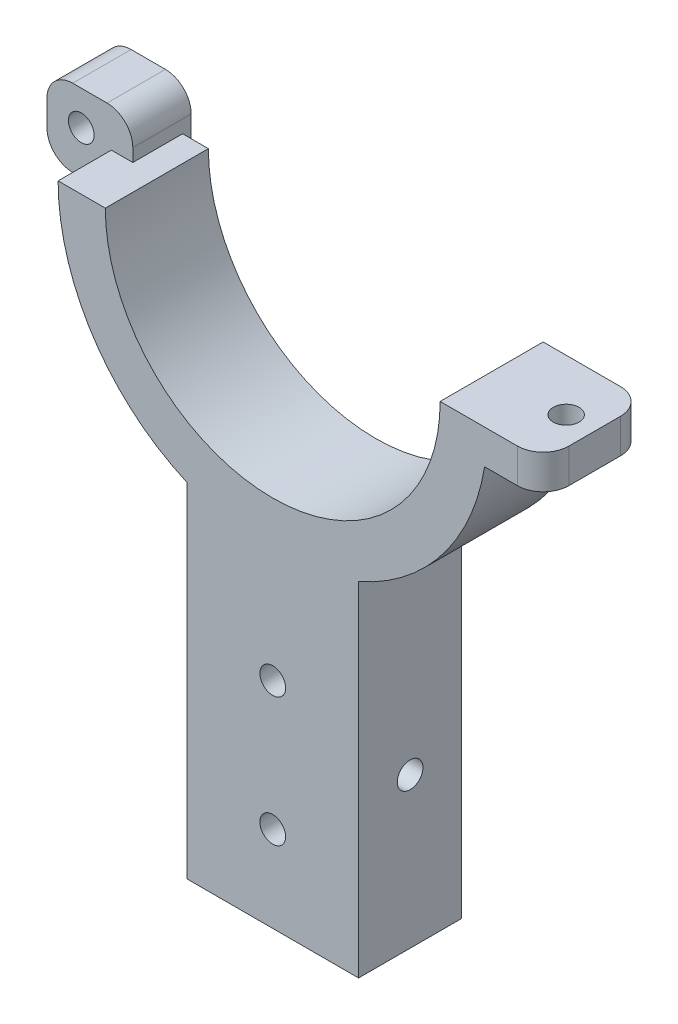
from build123d import *

# Parameters (mm, degrees)
BOSS_EXTRUDE8_DEPTH      = 12
SKETCH2_W                = 10
SKETCH2_H                = 9
BOSS_EXTRUDE9_DEPTH      = 1
BOSS_EXTRUDE9_DEPTH_BACK = 5.8
SKETCH3_R                = 1.5
CUT_EXTRUDE1_DEPTH       = 10
SKETCH4_W                = 8
SKETCH4_H                = 4
BOSS_EXTRUDE10_DEPTH     = 12
SKETCH5_R                = 1.5
CUT_EXTRUDE2_DEPTH       = 12
FILLET2_R                = 3
FILLET3_R                = 3
FILLET4_R                = 3
FILLET5_R                = 3
FILLET6_R                = 3
SKETCH6_R                = 1.5
CUT_EXTRUDE4_DEPTH       = 20
SKETCH7_R                = 1.5
CUT_EXTRUDE5_DEPTH       = 30


with BuildPart() as part:
    # Sketch1 → Boss-Extrude8 (new body)
    with BuildSketch(Plane.XY):
        with BuildLine():
            Line((25, 0), (19.5, 0))
            ThreePointArc((19.5, 0), (0, -19.5), (-19.5, 0))
            Line((-19.5, 0), (-25, 0))
            ThreePointArc((-25, 0), (-20.916500663, -13.693063938), (-10, -22.912878475))
            ThreePointArc((-10, -22.912878475), (0, -25), (10, -22.912878475))
            ThreePointArc((10, -22.912878475), (20.916500663, -13.693063938), (25, 0))
        make_face()
        with BuildLine():
            Line((10, -62.912878475), (10, -22.912878475))
            ThreePointArc((10, -22.912878475), (0, -25), (-10, -22.912878475))
            Line((-10, -22.912878475), (-10, -62.912878475))
            Line((-10, -62.912878475), (10, -62.912878475))
        make_face()
    extrude(amount=BOSS_EXTRUDE8_DEPTH)

    # Sketch2 → Boss-Extrude9 (add, two sides)
    with BuildSketch(Plane(origin=(0, 0, 0), x_dir=(-1, 0, 0), z_dir=(0, 0, -1))) as boss_extrude9_sk:
        with Locations((27.5, 0)):
            Rectangle(SKETCH2_W, SKETCH2_H)
    extrude(amount=BOSS_EXTRUDE9_DEPTH)
    extrude(boss_extrude9_sk.sketch, amount=-BOSS_EXTRUDE9_DEPTH_BACK)

    # Sketch3 → Cut-Extrude1 (cut)
    with BuildSketch(Plane(origin=(0, 0, -1), x_dir=(-1, 0, 0), z_dir=(0, 0, -1))):
        with Locations((28.5, 0.5)):
            Circle(SKETCH3_R)
    extrude(amount=-CUT_EXTRUDE1_DEPTH, mode=Mode.SUBTRACT)

    # Sketch4 → Boss-Extrude10 (add)
    with BuildSketch(Plane(origin=(0, 0, 0), x_dir=(-1, 0, 0), z_dir=(0, 0, -1))):
        with Locations((-27.5, -2)):
            Rectangle(SKETCH4_W, SKETCH4_H)
    extrude(amount=-BOSS_EXTRUDE10_DEPTH)

    # Sketch5 → Cut-Extrude2 (cut)
    with BuildSketch(Plane.XZ.offset(4)):
        with Locations((28.177925359, 6)):
            Circle(SKETCH5_R)
    extrude(amount=-CUT_EXTRUDE2_DEPTH, mode=Mode.SUBTRACT)

    # Fillet2
    fillet2_edges = [part.edges().sort_by_distance(p)[0] for p in [
        (-32.5, -4.5, 2.4),
    ]]
    fillet(fillet2_edges, radius=FILLET2_R)

    # Fillet3
    fillet3_edges = [part.edges().sort_by_distance(p)[0] for p in [
        (-32.5, 4.5, 2.4),
    ]]
    fillet(fillet3_edges, radius=FILLET3_R)

    # Fillet4
    fillet4_edges = [part.edges().sort_by_distance(p)[0] for p in [
        (-22.5, 4.5, 2.4),
    ]]
    fillet(fillet4_edges, radius=FILLET4_R)

    # Fillet5
    fillet5_edges = [part.edges().sort_by_distance(p)[0] for p in [
        (31.5, -2, 0),
    ]]
    fillet(fillet5_edges, radius=FILLET5_R)

    # Fillet6
    fillet6_edges = [part.edges().sort_by_distance(p)[0] for p in [
        (31.5, -2, 12),
    ]]
    fillet(fillet6_edges, radius=FILLET6_R)

    # Sketch6 → Cut-Extrude4 (cut)
    with BuildSketch(Plane(origin=(0, 0, 0), x_dir=(-1, 0, 0), z_dir=(0, 0, -1))):
        with Locations((0, -37.912878475)):
            Circle(SKETCH6_R)
        with Locations((0, -52.912878475)):
            Circle(SKETCH6_R)
    extrude(amount=-CUT_EXTRUDE4_DEPTH, mode=Mode.SUBTRACT)

    # Sketch7 → Cut-Extrude5 (cut)
    with BuildSketch(Plane(origin=(10, 0, 0), x_dir=(0, 0, -1), z_dir=(1, 0, 0))):
        with Locations((-6, -45.412878475)):
            Circle(SKETCH7_R)
    extrude(amount=-CUT_EXTRUDE5_DEPTH, mode=Mode.SUBTRACT)


solid = part.part
